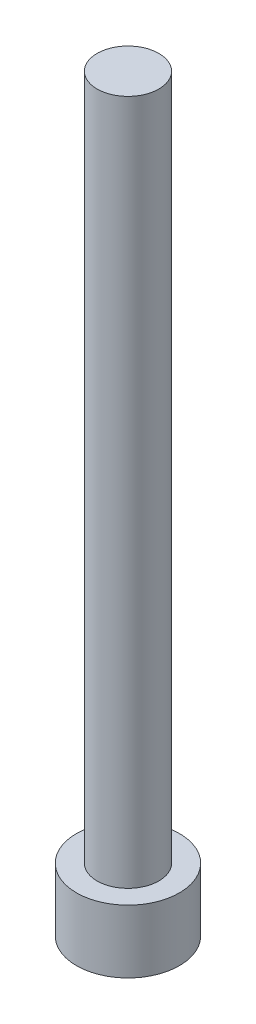
from build123d import *

# Parameters (mm, degrees)
SKETCH1_R           = 2.8575
BOSS_EXTRUDE1_DEPTH = 3.5052
CUT_EXTRUDE1_DEPTH  = 1.9558
SKETCH3_R           = 1.7145
BOSS_EXTRUDE2_DEPTH = 38.1


with BuildPart() as part:
    # Sketch1 → Boss-Extrude1 (new body)
    with BuildSketch(Plane(origin=(0, 0, 0), x_dir=(1, 0, 0), z_dir=(0, 1, 0))):
        Circle(SKETCH1_R)
    extrude(amount=BOSS_EXTRUDE1_DEPTH)

    # Sketch2 → Cut-Extrude1 (cut)
    with BuildSketch(Plane.XZ):
        Polygon((1.603951217, 0), (0.801975608, 1.3890625), (-0.801975608, 1.3890625), (-1.603951217, 0), (-0.801975608, -1.3890625), (0.801975608, -1.3890625), align=None)
    extrude(amount=-CUT_EXTRUDE1_DEPTH, mode=Mode.SUBTRACT)

    # Sketch3 → Boss-Extrude2 (add)
    with BuildSketch(Plane(origin=(0, 3.5052, 0), x_dir=(1, 0, 0), z_dir=(0, 1, 0))):
        Circle(SKETCH3_R)
    extrude(amount=BOSS_EXTRUDE2_DEPTH)


solid = part.part
